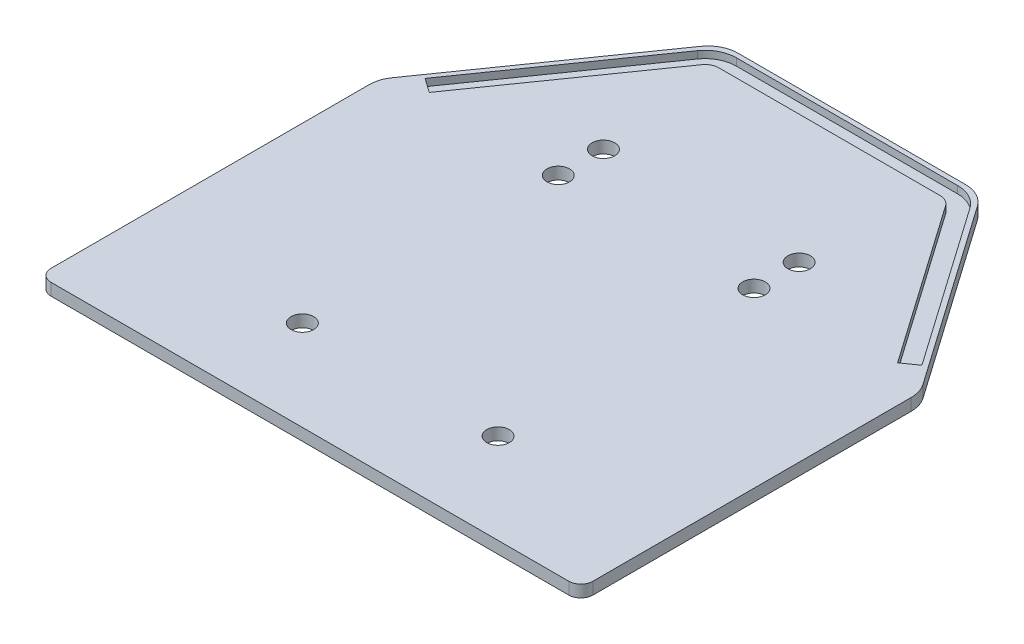
from build123d import *

# Parameters (mm, degrees)
SKETCH2_W               = 114.3
SKETCH2_H               = 101.6
BOSS_EXTRUDE1_DEPTH     = 2.54
SKETCH3_W               = 19.05
SKETCH3_H               = 38.1
BOSS_EXTRUDE2_DEPTH     = 2.54
TRUCKMOUNTINGHOLES_R    = 2.38125
CUT_EXTRUDE1_DEPTH      = 6.08
FILLET1_R               = 2.54
CUT_EXTRUDE3_DEPTH      = 3.54
CUT_EXTRUDE3_DEPTH_BACK = 3.54
BOSS_EXTRUDE3_DEPTH     = 2.54
CUT_EXTRUDE4_DEPTH      = 1.525958
FILLET2_R               = 6.35
SKETCH8_W               = 22.225
SKETCH8_H               = 2.54
BOSS_EXTRUDE4_DEPTH     = 2.54
CUT_EXTRUDE5_DEPTH      = 2.54
SKETCH10_W              = 60.325
SKETCH10_H              = 101.6
CUT_EXTRUDE6_DEPTH      = 2.54


with BuildPart() as part:
    # Sketch2 → Boss-Extrude1 (new body)
    with BuildSketch(Plane(origin=(0, 0, 0), x_dir=(1, 0, 0), z_dir=(0, 1, 0))):
        Rectangle(SKETCH2_W, SKETCH2_H)
    extrude(amount=BOSS_EXTRUDE1_DEPTH)

    # Sketch3 → Boss-Extrude2 (add)
    with BuildSketch(Plane(origin=(0, 2.54, 0), x_dir=(1, 0, 0), z_dir=(0, 1, 0))):
        with Locations((-20.6375, -31.75)):
            Rectangle(SKETCH3_W, SKETCH3_H)
        with Locations((20.6375, -31.75)):
            Rectangle(SKETCH3_W, SKETCH3_H)
        Polygon((-30.1625, 41.705647627), (-30.1625, 12.7), (-11.1125, 12.7), (-11.1125, 50.8), (-23.794565913, 50.8), align=None)
        Polygon((11.1125, 50.8), (11.1125, 12.7), (30.1625, 12.7), (30.1625, 41.705647627), (23.794565913, 50.8), align=None)
    extrude(amount=BOSS_EXTRUDE2_DEPTH)

    # TruckMountingHoles → Cut-Extrude1 (cut, through all)
    with BuildSketch(Plane(origin=(0, 0, 0), x_dir=(1, 0, 0), z_dir=(0, 1, 0))):
        with Locations((-20.6375, 22.225)):
            Circle(TRUCKMOUNTINGHOLES_R)
        with Locations((-20.6375, 31.75)):
            Circle(TRUCKMOUNTINGHOLES_R)
        with Locations((20.6375, 31.75)):
            Circle(TRUCKMOUNTINGHOLES_R)
        with Locations((20.6375, 22.225)):
            Circle(TRUCKMOUNTINGHOLES_R)
        with Locations((20.6375, -31.75)):
            Circle(TRUCKMOUNTINGHOLES_R)
        with Locations((-20.6375, -31.75)):
            Circle(TRUCKMOUNTINGHOLES_R)
    extrude(amount=CUT_EXTRUDE1_DEPTH, mode=Mode.SUBTRACT)

    # Fillet1
    fillet1_edges = [part.edges().sort_by_distance(p)[0] for p in [
        (57.15, 1.27, 50.8),
        (-57.15, 1.27, 50.8),
        (-57.15, 1.27, -50.8),
        (57.15, 1.27, -50.8),
    ]]
    fillet(fillet1_edges, radius=FILLET1_R)

    # Sketch5 → Cut-Extrude3 (cut, two sides)
    with BuildSketch(Plane(origin=(0, 2.54, 0), x_dir=(1, 0, 0), z_dir=(0, 1, 0))) as cut_extrude3_sk:
        with BuildLine():
            Line((54.61, 50.8), (36.197635735, 50.8))
            Line((36.197635735, 50.8), (57.15, 20.876922739))
            Line((57.15, 20.876922739), (57.15, 48.26))
            ThreePointArc((57.15, 48.26), (56.406051224, 50.056051224), (54.61, 50.8))
        make_face()
        with BuildLine():
            Line((-57.15, 20.876922739), (-36.197635735, 50.8))
            Line((-36.197635735, 50.8), (-54.61, 50.8))
            ThreePointArc((-54.61, 50.8), (-56.406051224, 50.056051224), (-57.15, 48.26))
            Line((-57.15, 48.26), (-57.15, 20.876922739))
        make_face()
    extrude(amount=CUT_EXTRUDE3_DEPTH, mode=Mode.SUBTRACT)
    extrude(cut_extrude3_sk.sketch, amount=-CUT_EXTRUDE3_DEPTH_BACK, mode=Mode.SUBTRACT)

    # Sketch5_5 → Boss-Extrude3 (add)
    with BuildSketch(Plane(origin=(0, 2.54, 0), x_dir=(1, 0, 0), z_dir=(0, 1, 0))):
        Polygon((36.197635735, 50.8), (27.305, 63.5), (-27.305, 63.5), (-36.197635735, 50.8), (-25.500724295, 50.8), (-23.794565913, 50.8), (-11.1125, 50.8), (11.1125, 50.8), (23.794565913, 50.8), align=None)
    extrude(amount=-BOSS_EXTRUDE3_DEPTH)

    # Sketch6 → Cut-Extrude4 (cut)
    with BuildSketch(Plane(origin=(0, 2.54, 0), x_dir=(1, 0, 0), z_dir=(0, 1, 0))):
        with BuildLine():
            Line((49.383451528, 23.776246966), (52.400388507, 25.888728981))
            Line((52.400388507, 25.888728981), (28.747959175, 59.667898786))
            ThreePointArc((28.747959175, 59.667898786), (26.387666917, 61.737819542), (23.338279075, 62.484))
            Line((23.338279075, 62.484), (-23.338279075, 62.484))
            ThreePointArc((-23.338279075, 62.484), (-26.387666917, 61.737819542), (-28.747959175, 59.667898786))
            Line((-28.747959175, 59.667898786), (-52.400388507, 25.888728981))
            Line((-52.400388507, 25.888728981), (-49.383451528, 23.776246966))
            Line((-49.383451528, 23.776246966), (-25.731022196, 57.555416771))
            ThreePointArc((-25.731022196, 57.555416771), (-24.687046774, 58.470958644), (-23.338279075, 58.801))
            Line((-23.338279075, 58.801), (23.338279075, 58.801))
            ThreePointArc((23.338279075, 58.801), (24.687046774, 58.470958644), (25.731022196, 57.555416771))
            Line((25.731022196, 57.555416771), (49.383451528, 23.776246966))
        make_face()
    extrude(amount=-CUT_EXTRUDE4_DEPTH, mode=Mode.SUBTRACT)

    # Fillet2
    fillet2_edges = [part.edges().sort_by_distance(p)[0] for p in [
        (57.15, 1.27, -20.876922739),
        (-57.15, 1.27, -20.876922739),
        (-27.305, 1.27, -63.5),
        (27.305, 1.27, -63.5),
    ]]
    fillet(fillet2_edges, radius=FILLET2_R)

    # Sketch8 → Boss-Extrude4 (add)
    with BuildSketch(Plane(origin=(0, 2.54, 0), x_dir=(1, 0, 0), z_dir=(0, 1, 0))):
        with Locations((0, -49.53)):
            Rectangle(SKETCH8_W, SKETCH8_H)
    extrude(amount=BOSS_EXTRUDE4_DEPTH)

    # Sketch9 → Cut-Extrude5 (cut)
    with BuildSketch(Plane.XY.offset(50.8)):
        with BuildLine():
            Line((6.346056871, 5.08), (-6.346056871, 5.08))
            ThreePointArc((-6.346056871, 5.08), (-5.941945474, 4.247288898), (-5.08, 3.91))
            Line((-5.08, 3.91), (5.08, 3.91))
            ThreePointArc((5.08, 3.91), (5.941945474, 4.247288898), (6.346056871, 5.08))
        make_face()
    extrude(amount=-CUT_EXTRUDE5_DEPTH, mode=Mode.SUBTRACT)

    # Sketch10 → Cut-Extrude6 (cut)
    with BuildSketch(Plane(origin=(0, 5.08, 0), x_dir=(1, 0, 0), z_dir=(0, 1, 0))):
        Rectangle(SKETCH10_W, SKETCH10_H)
    extrude(amount=-CUT_EXTRUDE6_DEPTH, mode=Mode.SUBTRACT)


solid = part.part
